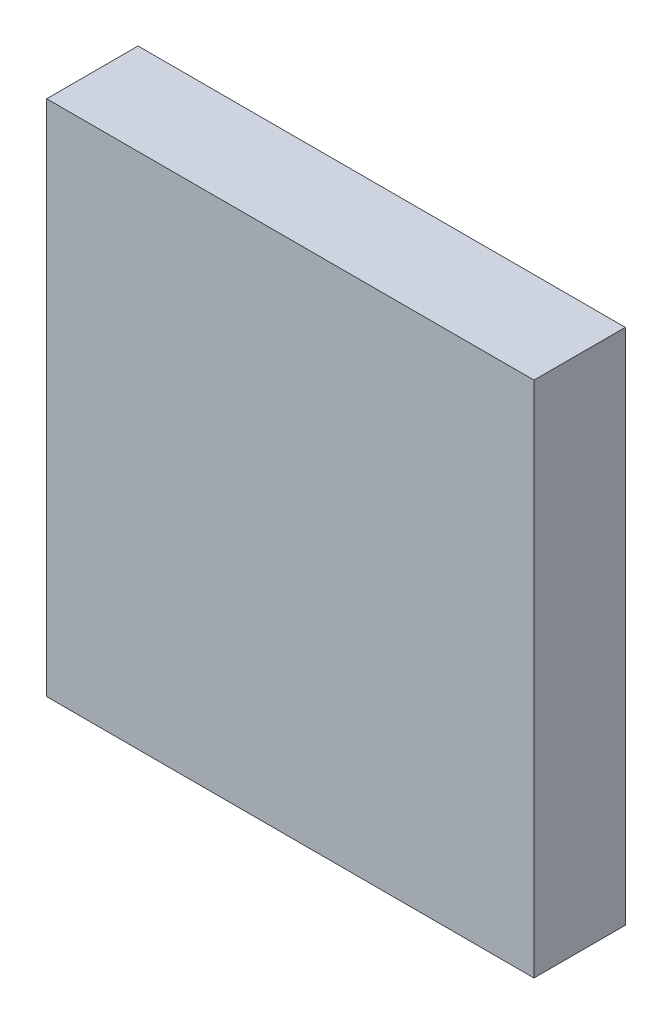
from build123d import *

# Parameters (mm, degrees)
SKETCH1_W           = 101.6
SKETCH1_H           = 19.05
BOSS_EXTRUDE1_DEPTH = 107.95


with BuildPart() as part:
    # Sketch1 → Boss-Extrude1 (new body)
    with BuildSketch(Plane(origin=(0, 0, 0), x_dir=(1, 0, 0), z_dir=(0, 1, 0))):
        Rectangle(SKETCH1_W, SKETCH1_H)
    extrude(amount=BOSS_EXTRUDE1_DEPTH)


solid = part.part
